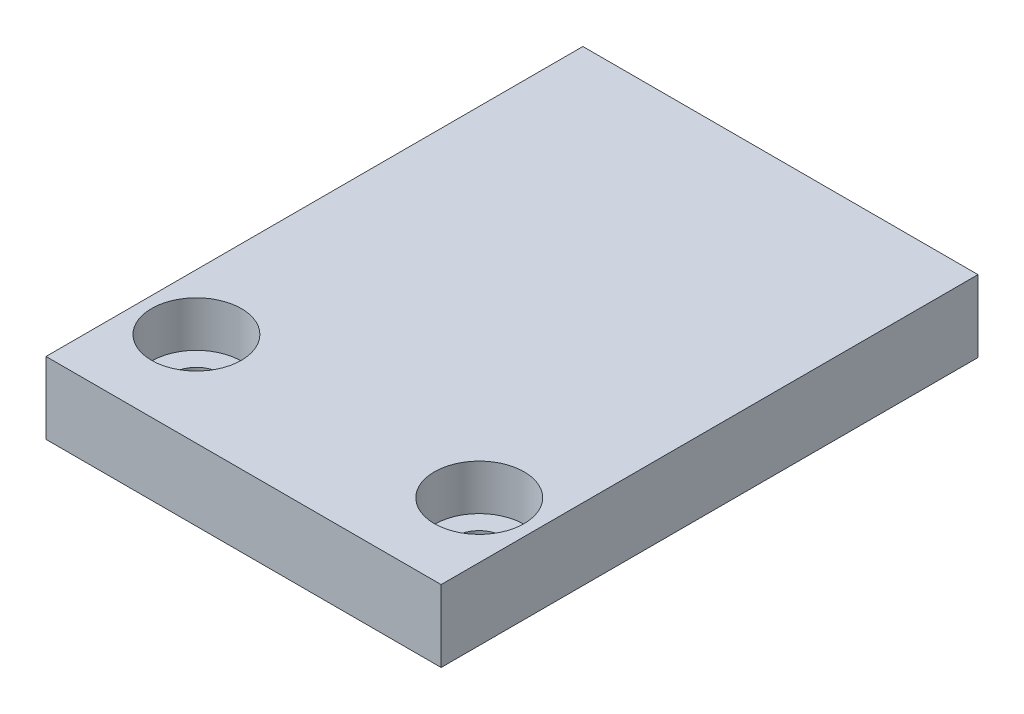
from build123d import *

# Parameters (mm, degrees)
SKETCH2_W                                       = 41.91
SKETCH2_H                                       = 56.947562
BOSS_EXTRUDE1_DEPTH                             = 7.62
CBORE_FOR_10_SOCKET_HEAD_CAP_SCREW1_D           = 5.1054
CBORE_FOR_10_SOCKET_HEAD_CAP_SCREW1_CBORE_D     = 9.525
CBORE_FOR_10_SOCKET_HEAD_CAP_SCREW1_CBORE_DEPTH = 4.826


with BuildPart() as part:
    # Sketch2 → Boss-Extrude1 (new body)
    with BuildSketch(Plane(origin=(0, 0, 0), x_dir=(1, 0, 0), z_dir=(0, 1, 0))):
        Rectangle(SKETCH2_W, SKETCH2_H)
    extrude(amount=BOSS_EXTRUDE1_DEPTH)

    # CBORE for #10 Socket Head Cap Screw1 (through all)
    with Locations(Plane(origin=(-20.955, 7.62, 28.473781), x_dir=(-1, 0, 0), z_dir=(0, 1, 0))):
        with Locations((-5.955, -10), (-35.955, -10)):
            CounterBoreHole(CBORE_FOR_10_SOCKET_HEAD_CAP_SCREW1_D / 2, CBORE_FOR_10_SOCKET_HEAD_CAP_SCREW1_CBORE_D / 2, CBORE_FOR_10_SOCKET_HEAD_CAP_SCREW1_CBORE_DEPTH)


solid = part.part
